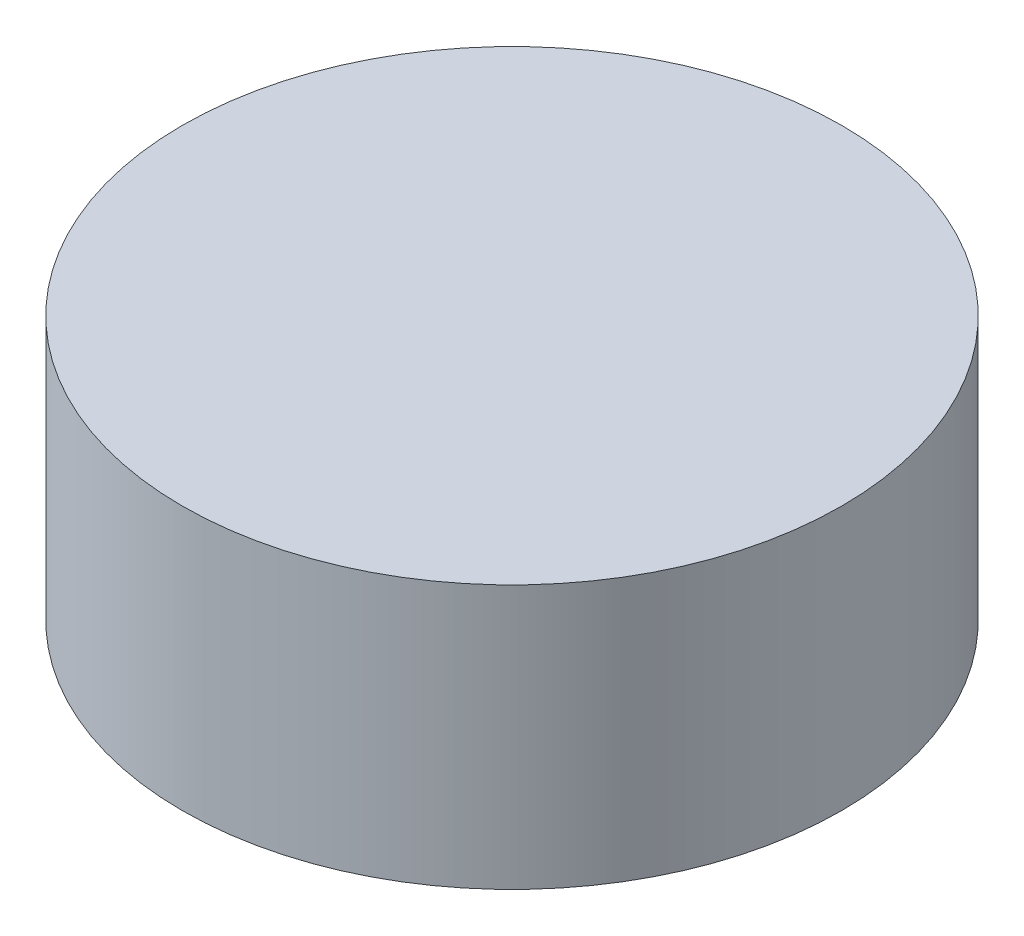
from build123d import *

# Parameters (mm, degrees)
SKETCH1_R           = 2.5
BOSS_EXTRUDE1_DEPTH = 2


with BuildPart() as part:
    # Sketch1 → Boss-Extrude1 (new body)
    with BuildSketch(Plane(origin=(0, 0, 0), x_dir=(1, 0, 0), z_dir=(0, 1, 0))):
        Circle(SKETCH1_R)
    extrude(amount=BOSS_EXTRUDE1_DEPTH)


solid = part.part
